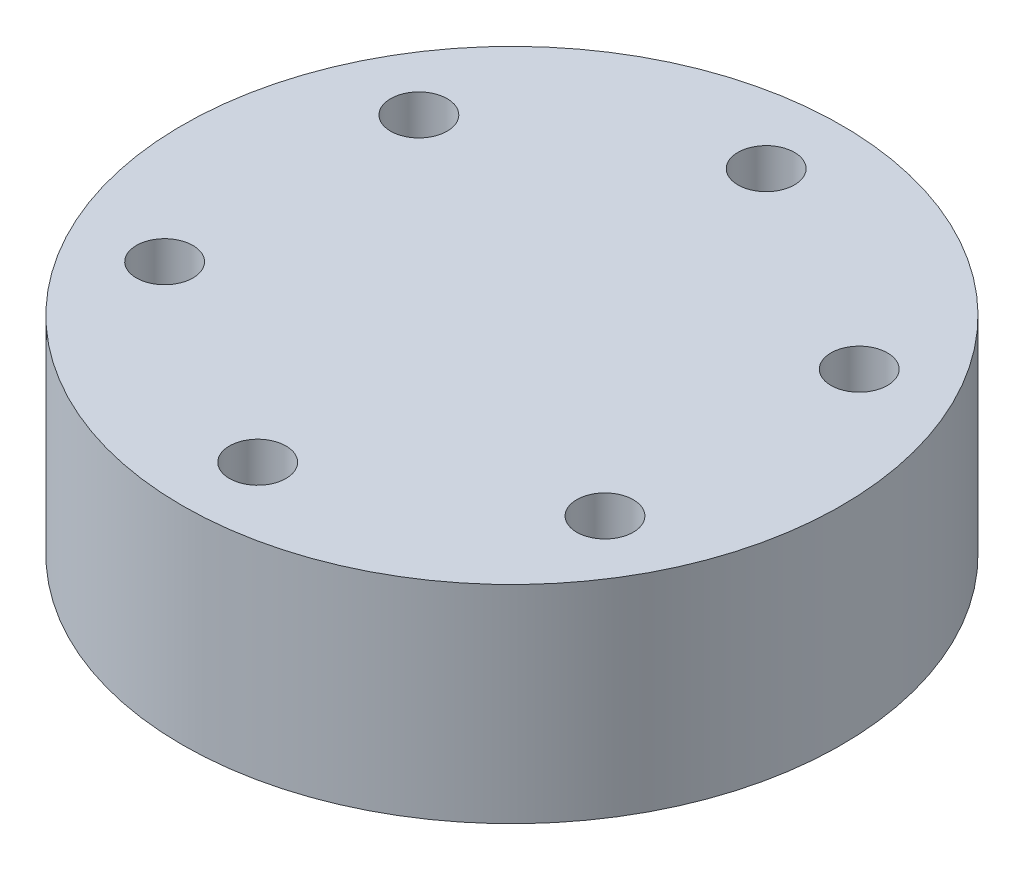
from build123d import *

# Parameters (mm, degrees)
SKETCH_1_R          = 17.5
EXTRUDE_1_DEPTH     = 11
SKETCH_2_R          = 1.5
CUT_EXTRUDE_1_DEPTH = 11


with BuildPart() as part:
    # 草图1 → 凸台-拉伸1 (new body)
    with BuildSketch(Plane(origin=(0, 0, 0), x_dir=(1, 0, 0), z_dir=(0, 1, 0))):
        Circle(SKETCH_1_R)
    extrude(amount=EXTRUDE_1_DEPTH)

    # 草图2 → 切除-拉伸1 (cut)
    with BuildSketch(Plane(origin=(0, 11, 0), x_dir=(1, 0, 0), z_dir=(0, 1, 0))):
        with Locations((0, 13.5)):
            Circle(SKETCH_2_R)
        with Locations((11.691342951, 6.75)):
            Circle(SKETCH_2_R)
        with Locations((11.691342951, -6.75)):
            Circle(SKETCH_2_R)
        with Locations((0, -13.5)):
            Circle(SKETCH_2_R)
        with Locations((-11.691342951, -6.75)):
            Circle(SKETCH_2_R)
        with Locations((-11.691342951, 6.75)):
            Circle(SKETCH_2_R)
    extrude(amount=-CUT_EXTRUDE_1_DEPTH, mode=Mode.SUBTRACT)


solid = part.part
